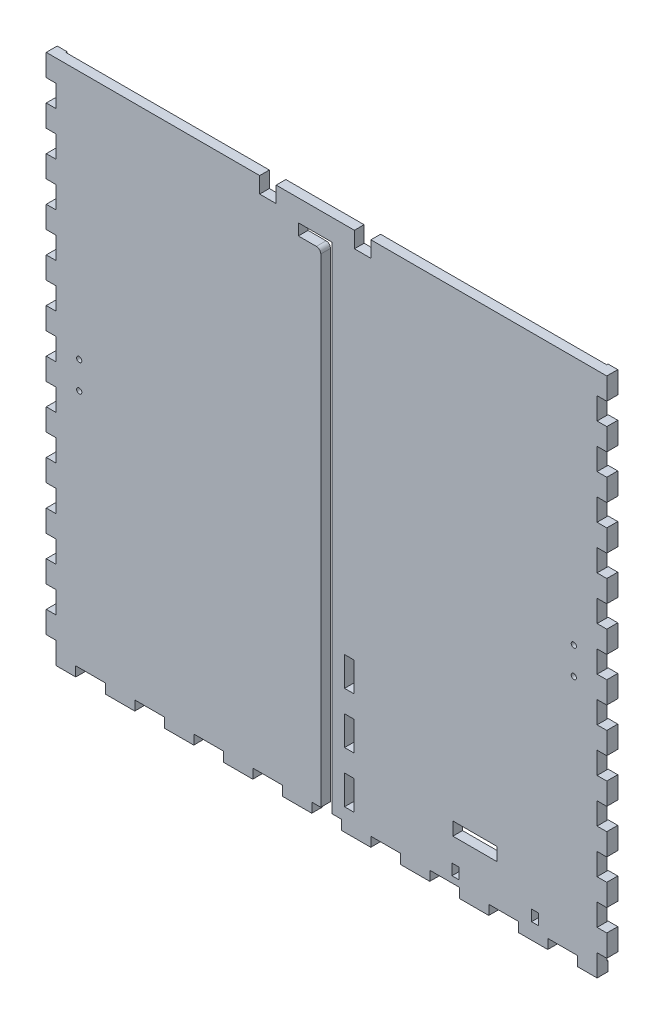
from build123d import *

# Parameters (mm, degrees)
SKETCH1_W              = 323.85
SKETCH1_H              = 139.7
BOSS_EXTRUDE1_DEPTH    = 5.588
SKETCH2_W              = 323.85
SKETCH2_H              = 139.7
SKETCH2_W_2            = 312.674
SKETCH2_H_2            = 128.524
BOSS_EXTRUDE2_DEPTH    = 298.45
SKETCH3_W              = 5.588
SKETCH3_H              = 16.933333333
SKETCH3_H_2            = 16.933333334
DOOR_SLOT_DEPTH        = 12.7
SKETCH4_W              = 6.35
SKETCH4_H              = 15.875
DOOR_GUIDE_HOLES_DEPTH = 5.588
LEVER_HOLES_R          = 1.5
LEVER_HOLES_W          = 25.4
LEVER_HOLES_H          = 7.62
LEVER_HOLES_W_2        = 4
LEVER_HOLES_H_2        = 6.35
LEVERHOLE_CUT_DEPTH    = 140.7
CUT_EXTRUDE2_REACH     = 325.85
SKETCH7_R              = 26.9875
CUT_EXTRUDE3_REACH     = 325.85
SKETCH8_R              = 3.175
SKETCH15_W             = 133.35
SKETCH15_H             = 338.00625338
CUT_EXTRUDE8_DEPTH     = 324.85
FRONT_BACK_W           = 5.588
FRONT_BACK_H           = 12.66825
FRONT_BACK_W_2         = 17.044736842
FRONT_BACK_H_2         = 5.588
CUT_EXTRUDE9_DEPTH     = 7.35
SKETCH16_W             = 9.525
SKETCH16_H             = 9.271
CUT_EXTRUDE10_DEPTH    = 7.35


with BuildPart() as part:
    # Sketch1 → Boss-Extrude1 (new body)
    with BuildSketch(Plane(origin=(0, 0, 0), x_dir=(1, 0, 0), z_dir=(0, 1, 0))):
        Rectangle(SKETCH1_W, SKETCH1_H)
    extrude(amount=BOSS_EXTRUDE1_DEPTH)

    # Sketch2 → Boss-Extrude2 (add)
    with BuildSketch(Plane(origin=(0, 5.588, 0), x_dir=(1, 0, 0), z_dir=(0, 1, 0))):
        Rectangle(SKETCH2_W, SKETCH2_H)
        Rectangle(SKETCH2_W_2, SKETCH2_H_2, mode=Mode.SUBTRACT)
    extrude(amount=BOSS_EXTRUDE2_DEPTH)

    # Sketch3 → Door Slot (cut)
    with BuildSketch(Plane.XY.offset(69.85)):
        with BuildLine():
            Line((-3.302, 282.448), (-3.302, 5.588))
            Line((-3.302, 5.588), (3.302, 5.588))
            Line((3.302, 5.588), (3.302, 291.592))
            Line((3.302, 291.592), (-16.256, 291.592))
            Line((-16.256, 291.592), (-16.256, 284.988))
            Line((-16.256, 284.988), (-5.842, 284.988))
            ThreePointArc((-5.842, 284.988), (-4.045948776, 284.244051224), (-3.302, 282.448))
        make_face()
        with Locations((13.208, 80.433333334)):
            Rectangle(SKETCH3_W, SKETCH3_H)
        with Locations((13.208, 50.8)):
            Rectangle(SKETCH3_W, SKETCH3_H_2)
        with Locations((13.208, 21.166666667)):
            Rectangle(SKETCH3_W, SKETCH3_H)
    extrude(amount=-DOOR_SLOT_DEPTH, mode=Mode.SUBTRACT)

    # Sketch4 → Door Guide Holes (cut)
    with BuildSketch(Plane.XY.offset(-64.262)):
        with Locations((-19.431, 283.4005)):
            Rectangle(SKETCH4_W, SKETCH4_H)
        with Locations((-19.431, 254.8255)):
            Rectangle(SKETCH4_W, SKETCH4_H)
        with Locations((-19.431, 226.2505)):
            Rectangle(SKETCH4_W, SKETCH4_H)
        with Locations((-19.431, 197.6755)):
            Rectangle(SKETCH4_W, SKETCH4_H)
        with Locations((-19.431, 169.1005)):
            Rectangle(SKETCH4_W, SKETCH4_H)
        with Locations((-19.431, 140.5255)):
            Rectangle(SKETCH4_W, SKETCH4_H)
        with Locations((-19.431, 111.9505)):
            Rectangle(SKETCH4_W, SKETCH4_H)
        with Locations((-19.431, 83.3755)):
            Rectangle(SKETCH4_W, SKETCH4_H)
        with Locations((-19.431, 54.8005)):
            Rectangle(SKETCH4_W, SKETCH4_H)
        with Locations((-19.431, 26.2255)):
            Rectangle(SKETCH4_W, SKETCH4_H)
    door_guide_holes = extrude(amount=-DOOR_GUIDE_HOLES_DEPTH, mode=Mode.SUBTRACT)

    # Mirror1: Door Guide Holes across plane
    add(door_guide_holes.mirror(Plane.ZY.offset(6.477)), mode=Mode.SUBTRACT)

    # Lever Holes → LeverHole Cut (cut, through all)
    with BuildSketch(Plane.XY.offset(69.85)):
        with Locations((142.875, 159.894)):
            Circle(LEVER_HOLES_R)
        with Locations((142.875, 144.144)):
            Circle(LEVER_HOLES_R)
        with Locations((-142.875, 159.894)):
            Circle(LEVER_HOLES_R)
        with Locations((-142.875, 144.144)):
            Circle(LEVER_HOLES_R)
        with Locations((85.725, 33.1129894)):
            Rectangle(LEVER_HOLES_W, LEVER_HOLES_H)
        with Locations((74.475, 12.413)):
            Rectangle(LEVER_HOLES_W_2, LEVER_HOLES_H_2)
        with Locations((120.4749932, 12.413)):
            Rectangle(LEVER_HOLES_W_2, LEVER_HOLES_H_2)
    extrude(amount=-LEVERHOLE_CUT_DEPTH, mode=Mode.SUBTRACT)

    # Sketch7 → Cut-Extrude2 (cut, up to next)
    with BuildSketch(Plane(origin=(161.925, 0, 0), x_dir=(0, 0, -1), z_dir=(1, 0, 0)), mode=Mode.PRIVATE) as cut_extrude2_sk1:
        with Locations((0, 55.372)):
            Circle(SKETCH7_R)
    cut_extrude2_tool1 = extrude(cut_extrude2_sk1.sketch, amount=-CUT_EXTRUDE2_REACH, mode=Mode.PRIVATE) & part.part
    add(cut_extrude2_tool1.solids().sort_by_distance((161.925, 55.372, 0))[0], mode=Mode.SUBTRACT)
    # Sketch7 → Cut-Extrude2 (cut, up to next)
    with BuildSketch(Plane(origin=(161.925, 0, 0), x_dir=(0, 0, -1), z_dir=(1, 0, 0)), mode=Mode.PRIVATE) as cut_extrude2_sk2:
        with BuildLine():
            Line((-37.211, 89.408), (-37.211, 92.583))
            Line((-37.211, 92.583), (-34.036, 92.583))
            ThreePointArc((-34.036, 92.583), (-39.45606403, 94.82806403), (-37.211, 89.408))
        make_face()
    cut_extrude2_tool2 = extrude(cut_extrude2_sk2.sketch, amount=-CUT_EXTRUDE2_REACH, mode=Mode.PRIVATE) & part.part
    add(cut_extrude2_tool2.solids().sort_by_distance((161.925, 93.032171, 37.660171))[0], mode=Mode.SUBTRACT)
    # Sketch7 → Cut-Extrude2 (cut, up to next)
    with BuildSketch(Plane(origin=(161.925, 0, 0), x_dir=(0, 0, -1), z_dir=(1, 0, 0)), mode=Mode.PRIVATE) as cut_extrude2_sk3:
        with BuildLine():
            Line((-34.036, 92.583), (-37.211, 92.583))
            Line((-37.211, 92.583), (-37.211, 89.408))
            ThreePointArc((-37.211, 89.408), (-34.96593597, 90.33793597), (-34.036, 92.583))
        make_face()
    cut_extrude2_tool3 = extrude(cut_extrude2_sk3.sketch, amount=-CUT_EXTRUDE2_REACH, mode=Mode.PRIVATE) & part.part
    add(cut_extrude2_tool3.solids().sort_by_distance((161.925, 91.235488, 35.863488))[0], mode=Mode.SUBTRACT)
    # Sketch7 → Cut-Extrude2 (cut, up to next)
    with BuildSketch(Plane(origin=(161.925, 0, 0), x_dir=(0, 0, -1), z_dir=(1, 0, 0)), mode=Mode.PRIVATE) as cut_extrude2_sk4:
        with BuildLine():
            Line((-37.211, 89.408), (-37.211, 92.583))
            Line((-37.211, 92.583), (-34.036, 92.583))
            ThreePointArc((-34.036, 92.583), (-39.45606403, 94.82806403), (-37.211, 89.408))
        make_face()
    cut_extrude2_tool4 = extrude(cut_extrude2_sk4.sketch, amount=-CUT_EXTRUDE2_REACH, mode=Mode.PRIVATE) & part.part
    add(cut_extrude2_tool4.solids().sort_by_distance((161.925, 93.032171, 37.660171))[0], mode=Mode.SUBTRACT)
    # Sketch7 → Cut-Extrude2 (cut, up to next)
    with BuildSketch(Plane(origin=(161.925, 0, 0), x_dir=(0, 0, -1), z_dir=(1, 0, 0)), mode=Mode.PRIVATE) as cut_extrude2_sk5:
        with BuildLine():
            Line((-34.036, 92.583), (-37.211, 92.583))
            Line((-37.211, 92.583), (-37.211, 89.408))
            ThreePointArc((-37.211, 89.408), (-34.96593597, 90.33793597), (-34.036, 92.583))
        make_face()
    cut_extrude2_tool5 = extrude(cut_extrude2_sk5.sketch, amount=-CUT_EXTRUDE2_REACH, mode=Mode.PRIVATE) & part.part
    add(cut_extrude2_tool5.solids().sort_by_distance((161.925, 91.235488, 35.863488))[0], mode=Mode.SUBTRACT)
    # Sketch7 → Cut-Extrude2 (cut, up to next)
    with BuildSketch(Plane(origin=(161.925, 0, 0), x_dir=(0, 0, -1), z_dir=(1, 0, 0)), mode=Mode.PRIVATE) as cut_extrude2_sk6:
        with BuildLine():
            ThreePointArc((40.386, 92.583), (37.211, 95.758), (34.036, 92.583))
            Line((34.036, 92.583), (37.211, 92.583))
            Line((37.211, 92.583), (37.211, 89.408))
            ThreePointArc((37.211, 89.408), (39.45606403, 90.33793597), (40.386, 92.583))
        make_face()
    cut_extrude2_tool6 = extrude(cut_extrude2_sk6.sketch, amount=-CUT_EXTRUDE2_REACH, mode=Mode.PRIVATE) & part.part
    add(cut_extrude2_tool6.solids().sort_by_distance((161.925, 93.032171, -37.660171))[0], mode=Mode.SUBTRACT)
    # Sketch7 → Cut-Extrude2 (cut, up to next)
    with BuildSketch(Plane(origin=(161.925, 0, 0), x_dir=(0, 0, -1), z_dir=(1, 0, 0)), mode=Mode.PRIVATE) as cut_extrude2_sk7:
        with BuildLine():
            Line((37.211, 92.583), (34.036, 92.583))
            ThreePointArc((34.036, 92.583), (34.96593597, 90.33793597), (37.211, 89.408))
            Line((37.211, 89.408), (37.211, 92.583))
        make_face()
    cut_extrude2_tool7 = extrude(cut_extrude2_sk7.sketch, amount=-CUT_EXTRUDE2_REACH, mode=Mode.PRIVATE) & part.part
    add(cut_extrude2_tool7.solids().sort_by_distance((161.925, 91.235488, -35.863488))[0], mode=Mode.SUBTRACT)
    # Sketch7 → Cut-Extrude2 (cut, up to next)
    with BuildSketch(Plane(origin=(161.925, 0, 0), x_dir=(0, 0, -1), z_dir=(1, 0, 0)), mode=Mode.PRIVATE) as cut_extrude2_sk8:
        with BuildLine():
            ThreePointArc((40.386, 92.583), (37.211, 95.758), (34.036, 92.583))
            Line((34.036, 92.583), (37.211, 92.583))
            Line((37.211, 92.583), (37.211, 89.408))
            ThreePointArc((37.211, 89.408), (39.45606403, 90.33793597), (40.386, 92.583))
        make_face()
    cut_extrude2_tool8 = extrude(cut_extrude2_sk8.sketch, amount=-CUT_EXTRUDE2_REACH, mode=Mode.PRIVATE) & part.part
    add(cut_extrude2_tool8.solids().sort_by_distance((161.925, 93.032171, -37.660171))[0], mode=Mode.SUBTRACT)
    # Sketch7 → Cut-Extrude2 (cut, up to next)
    with BuildSketch(Plane(origin=(161.925, 0, 0), x_dir=(0, 0, -1), z_dir=(1, 0, 0)), mode=Mode.PRIVATE) as cut_extrude2_sk9:
        with BuildLine():
            Line((37.211, 92.583), (34.036, 92.583))
            ThreePointArc((34.036, 92.583), (34.96593597, 90.33793597), (37.211, 89.408))
            Line((37.211, 89.408), (37.211, 92.583))
        make_face()
    cut_extrude2_tool9 = extrude(cut_extrude2_sk9.sketch, amount=-CUT_EXTRUDE2_REACH, mode=Mode.PRIVATE) & part.part
    add(cut_extrude2_tool9.solids().sort_by_distance((161.925, 91.235488, -35.863488))[0], mode=Mode.SUBTRACT)
    # Sketch7 → Cut-Extrude2 (cut, up to next)
    with BuildSketch(Plane(origin=(161.925, 0, 0), x_dir=(0, 0, -1), z_dir=(1, 0, 0)), mode=Mode.PRIVATE) as cut_extrude2_sk10:
        with BuildLine():
            ThreePointArc((-34.036, 18.161), (-34.96593597, 20.40606403), (-37.211, 21.336))
            Line((-37.211, 21.336), (-37.211, 18.161))
            Line((-37.211, 18.161), (-34.036, 18.161))
        make_face()
    cut_extrude2_tool10 = extrude(cut_extrude2_sk10.sketch, amount=-CUT_EXTRUDE2_REACH, mode=Mode.PRIVATE) & part.part
    add(cut_extrude2_tool10.solids().sort_by_distance((161.925, 19.508512, 35.863488))[0], mode=Mode.SUBTRACT)
    # Sketch7 → Cut-Extrude2 (cut, up to next)
    with BuildSketch(Plane(origin=(161.925, 0, 0), x_dir=(0, 0, -1), z_dir=(1, 0, 0)), mode=Mode.PRIVATE) as cut_extrude2_sk11:
        with BuildLine():
            Line((-37.211, 18.161), (-37.211, 21.336))
            ThreePointArc((-37.211, 21.336), (-39.45606403, 15.91593597), (-34.036, 18.161))
            Line((-34.036, 18.161), (-37.211, 18.161))
        make_face()
    cut_extrude2_tool11 = extrude(cut_extrude2_sk11.sketch, amount=-CUT_EXTRUDE2_REACH, mode=Mode.PRIVATE) & part.part
    add(cut_extrude2_tool11.solids().sort_by_distance((161.925, 17.711829, 37.660171))[0], mode=Mode.SUBTRACT)
    # Sketch7 → Cut-Extrude2 (cut, up to next)
    with BuildSketch(Plane(origin=(161.925, 0, 0), x_dir=(0, 0, -1), z_dir=(1, 0, 0)), mode=Mode.PRIVATE) as cut_extrude2_sk12:
        with BuildLine():
            ThreePointArc((-34.036, 18.161), (-34.96593597, 20.40606403), (-37.211, 21.336))
            Line((-37.211, 21.336), (-37.211, 18.161))
            Line((-37.211, 18.161), (-34.036, 18.161))
        make_face()
    cut_extrude2_tool12 = extrude(cut_extrude2_sk12.sketch, amount=-CUT_EXTRUDE2_REACH, mode=Mode.PRIVATE) & part.part
    add(cut_extrude2_tool12.solids().sort_by_distance((161.925, 19.508512, 35.863488))[0], mode=Mode.SUBTRACT)
    # Sketch7 → Cut-Extrude2 (cut, up to next)
    with BuildSketch(Plane(origin=(161.925, 0, 0), x_dir=(0, 0, -1), z_dir=(1, 0, 0)), mode=Mode.PRIVATE) as cut_extrude2_sk13:
        with BuildLine():
            Line((-37.211, 18.161), (-37.211, 21.336))
            ThreePointArc((-37.211, 21.336), (-39.45606403, 15.91593597), (-34.036, 18.161))
            Line((-34.036, 18.161), (-37.211, 18.161))
        make_face()
    cut_extrude2_tool13 = extrude(cut_extrude2_sk13.sketch, amount=-CUT_EXTRUDE2_REACH, mode=Mode.PRIVATE) & part.part
    add(cut_extrude2_tool13.solids().sort_by_distance((161.925, 17.711829, 37.660171))[0], mode=Mode.SUBTRACT)
    # Sketch7 → Cut-Extrude2 (cut, up to next)
    with BuildSketch(Plane(origin=(161.925, 0, 0), x_dir=(0, 0, -1), z_dir=(1, 0, 0)), mode=Mode.PRIVATE) as cut_extrude2_sk14:
        with BuildLine():
            ThreePointArc((40.386, 18.161), (39.45606403, 20.40606403), (37.211, 21.336))
            Line((37.211, 21.336), (37.211, 18.161))
            Line((37.211, 18.161), (34.036, 18.161))
            ThreePointArc((34.036, 18.161), (37.211, 14.986), (40.386, 18.161))
        make_face()
    cut_extrude2_tool14 = extrude(cut_extrude2_sk14.sketch, amount=-CUT_EXTRUDE2_REACH, mode=Mode.PRIVATE) & part.part
    add(cut_extrude2_tool14.solids().sort_by_distance((161.925, 17.711829, -37.660171))[0], mode=Mode.SUBTRACT)
    # Sketch7 → Cut-Extrude2 (cut, up to next)
    with BuildSketch(Plane(origin=(161.925, 0, 0), x_dir=(0, 0, -1), z_dir=(1, 0, 0)), mode=Mode.PRIVATE) as cut_extrude2_sk15:
        with BuildLine():
            Line((37.211, 18.161), (37.211, 21.336))
            ThreePointArc((37.211, 21.336), (34.96593597, 20.40606403), (34.036, 18.161))
            Line((34.036, 18.161), (37.211, 18.161))
        make_face()
    cut_extrude2_tool15 = extrude(cut_extrude2_sk15.sketch, amount=-CUT_EXTRUDE2_REACH, mode=Mode.PRIVATE) & part.part
    add(cut_extrude2_tool15.solids().sort_by_distance((161.925, 19.508512, -35.863488))[0], mode=Mode.SUBTRACT)
    # Sketch7 → Cut-Extrude2 (cut, up to next)
    with BuildSketch(Plane(origin=(161.925, 0, 0), x_dir=(0, 0, -1), z_dir=(1, 0, 0)), mode=Mode.PRIVATE) as cut_extrude2_sk16:
        with BuildLine():
            ThreePointArc((40.386, 18.161), (39.45606403, 20.40606403), (37.211, 21.336))
            Line((37.211, 21.336), (37.211, 18.161))
            Line((37.211, 18.161), (34.036, 18.161))
            ThreePointArc((34.036, 18.161), (37.211, 14.986), (40.386, 18.161))
        make_face()
    cut_extrude2_tool16 = extrude(cut_extrude2_sk16.sketch, amount=-CUT_EXTRUDE2_REACH, mode=Mode.PRIVATE) & part.part
    add(cut_extrude2_tool16.solids().sort_by_distance((161.925, 17.711829, -37.660171))[0], mode=Mode.SUBTRACT)
    # Sketch7 → Cut-Extrude2 (cut, up to next)
    with BuildSketch(Plane(origin=(161.925, 0, 0), x_dir=(0, 0, -1), z_dir=(1, 0, 0)), mode=Mode.PRIVATE) as cut_extrude2_sk17:
        with BuildLine():
            Line((37.211, 18.161), (37.211, 21.336))
            ThreePointArc((37.211, 21.336), (34.96593597, 20.40606403), (34.036, 18.161))
            Line((34.036, 18.161), (37.211, 18.161))
        make_face()
    cut_extrude2_tool17 = extrude(cut_extrude2_sk17.sketch, amount=-CUT_EXTRUDE2_REACH, mode=Mode.PRIVATE) & part.part
    add(cut_extrude2_tool17.solids().sort_by_distance((161.925, 19.508512, -35.863488))[0], mode=Mode.SUBTRACT)

    # Sketch8 → Cut-Extrude3 (cut, up to next)
    with BuildSketch(Plane.ZY.offset(161.925), mode=Mode.PRIVATE) as cut_extrude3_sk1:
        with Locations((0, 19.05)):
            Circle(SKETCH8_R)
    cut_extrude3_tool1 = extrude(cut_extrude3_sk1.sketch, amount=-CUT_EXTRUDE3_REACH, mode=Mode.PRIVATE) & part.part
    add(cut_extrude3_tool1.solids().sort_by_distance((-161.925, 19.05, 0))[0], mode=Mode.SUBTRACT)

    # Sketch15 → Cut-Extrude8 (cut, through all)
    with BuildSketch(Plane.ZY.offset(161.925)):
        with Locations((-3.175, 135.03487331)):
            Rectangle(SKETCH15_W, SKETCH15_H)
    extrude(amount=-CUT_EXTRUDE8_DEPTH, mode=Mode.SUBTRACT)

    # Front/Back → Cut-Extrude9 (cut, through all)
    with BuildSketch(Plane.XY.offset(69.85)):
        with Locations((-159.131, 6.334125)):
            Rectangle(FRONT_BACK_W, FRONT_BACK_H)
        with Locations((-136.357894737, 2.794)):
            Rectangle(FRONT_BACK_W_2, FRONT_BACK_H_2)
        with Locations((-159.131, 31.670625)):
            Rectangle(FRONT_BACK_W, FRONT_BACK_H)
        with Locations((-102.268421053, 2.794)):
            Rectangle(FRONT_BACK_W_2, FRONT_BACK_H_2)
        with Locations((-159.131, 57.007125)):
            Rectangle(FRONT_BACK_W, FRONT_BACK_H)
        with Locations((-68.178947368, 2.794)):
            Rectangle(FRONT_BACK_W_2, FRONT_BACK_H_2)
        with Locations((-159.131, 82.343625)):
            Rectangle(FRONT_BACK_W, FRONT_BACK_H)
        with Locations((-34.089473684, 2.794)):
            Rectangle(FRONT_BACK_W_2, FRONT_BACK_H_2)
        with Locations((-159.131, 107.680125)):
            Rectangle(FRONT_BACK_W, FRONT_BACK_H)
        with Locations((0, 2.794)):
            Rectangle(FRONT_BACK_W_2, FRONT_BACK_H_2)
        with Locations((-159.131, 133.016625)):
            Rectangle(FRONT_BACK_W, FRONT_BACK_H)
        with Locations((34.089473684, 2.794)):
            Rectangle(FRONT_BACK_W_2, FRONT_BACK_H_2)
        with Locations((-159.131, 158.353125)):
            Rectangle(FRONT_BACK_W, FRONT_BACK_H)
        with Locations((68.178947368, 2.794)):
            Rectangle(FRONT_BACK_W_2, FRONT_BACK_H_2)
        with Locations((-159.131, 183.689625)):
            Rectangle(FRONT_BACK_W, FRONT_BACK_H)
        with Locations((102.268421053, 2.794)):
            Rectangle(FRONT_BACK_W_2, FRONT_BACK_H_2)
        with Locations((-159.131, 209.026125)):
            Rectangle(FRONT_BACK_W, FRONT_BACK_H)
        with Locations((136.357894737, 2.794)):
            Rectangle(FRONT_BACK_W_2, FRONT_BACK_H_2)
        with Locations((-159.131, 234.362625)):
            Rectangle(FRONT_BACK_W, FRONT_BACK_H)
        with Locations((159.131, 6.334125)):
            Rectangle(FRONT_BACK_W, FRONT_BACK_H)
        with Locations((-159.131, 259.699125)):
            Rectangle(FRONT_BACK_W, FRONT_BACK_H)
        with Locations((159.131, 31.670625)):
            Rectangle(FRONT_BACK_W, FRONT_BACK_H)
        with Locations((-159.131, 285.035625)):
            Rectangle(FRONT_BACK_W, FRONT_BACK_H)
        with Locations((159.131, 57.007125)):
            Rectangle(FRONT_BACK_W, FRONT_BACK_H)
        with Locations((159.131, 82.343625)):
            Rectangle(FRONT_BACK_W, FRONT_BACK_H)
        with Locations((159.131, 107.680125)):
            Rectangle(FRONT_BACK_W, FRONT_BACK_H)
        with Locations((159.131, 133.016625)):
            Rectangle(FRONT_BACK_W, FRONT_BACK_H)
        with Locations((159.131, 158.353125)):
            Rectangle(FRONT_BACK_W, FRONT_BACK_H)
        with Locations((159.131, 183.689625)):
            Rectangle(FRONT_BACK_W, FRONT_BACK_H)
        with Locations((159.131, 209.026125)):
            Rectangle(FRONT_BACK_W, FRONT_BACK_H)
        with Locations((159.131, 234.362625)):
            Rectangle(FRONT_BACK_W, FRONT_BACK_H)
        with Locations((159.131, 259.699125)):
            Rectangle(FRONT_BACK_W, FRONT_BACK_H)
        with Locations((159.131, 285.035625)):
            Rectangle(FRONT_BACK_W, FRONT_BACK_H)
    extrude(amount=-CUT_EXTRUDE9_DEPTH, mode=Mode.SUBTRACT)

    # Sketch16 → Cut-Extrude10 (cut, through all)
    with BuildSketch(Plane.XY.offset(69.85)):
        with Locations((-33.8455, 299.4025)):
            Rectangle(SKETCH16_W, SKETCH16_H)
        with Locations((20.8915, 299.4025)):
            Rectangle(SKETCH16_W, SKETCH16_H)
    extrude(amount=-CUT_EXTRUDE10_DEPTH, mode=Mode.SUBTRACT)


solid = part.part
